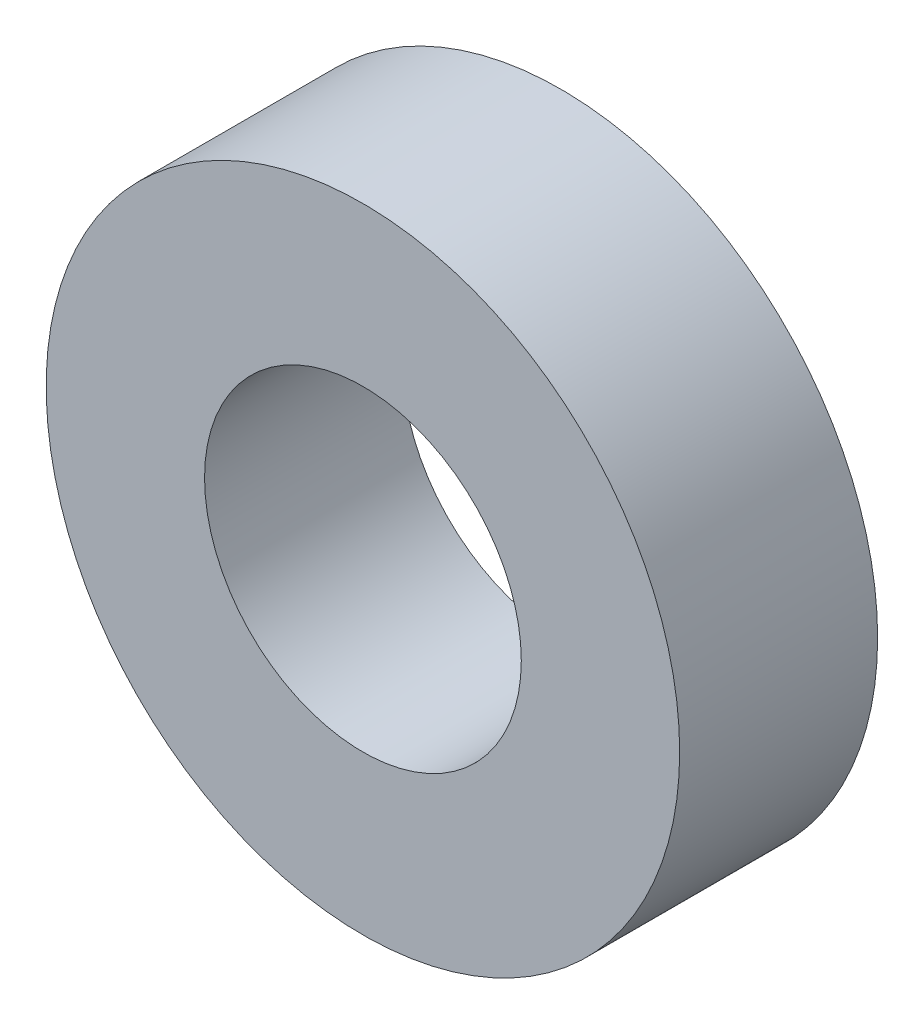
from build123d import *

# Parameters (mm, degrees)
ESQUISSE1_R      = 8
ESQUISSE1_R_2    = 4
EXTRUSION1_DEPTH = 5


with BuildPart() as part:
    # Esquisse1 → Extrusion1 (new body)
    with BuildSketch(Plane.XY):
        Circle(ESQUISSE1_R)
        Circle(ESQUISSE1_R_2, mode=Mode.SUBTRACT)
    extrude(amount=EXTRUSION1_DEPTH)


solid = part.part
